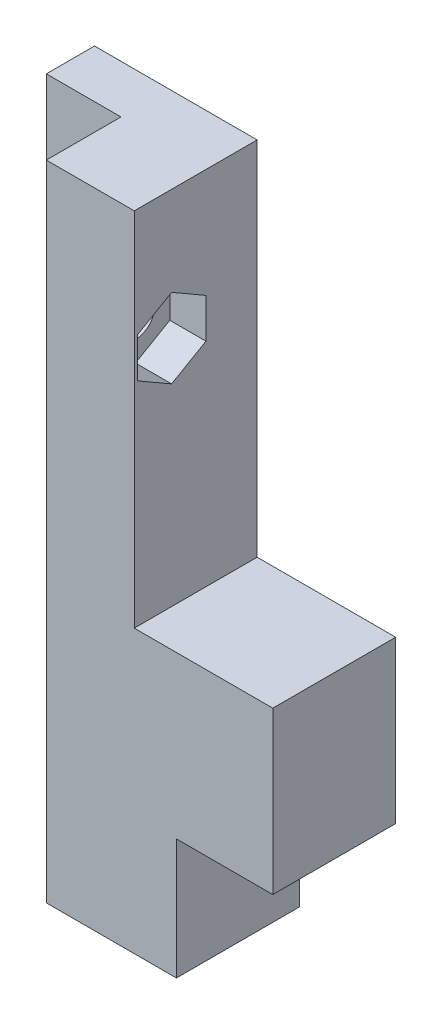
from build123d import *

# Parameters (mm, degrees)
SALIENTE_EXTRUIR1_DEPTH = 4
SALIENTE_EXTRUIR2_DEPTH = 6.2
CORTAR_EXTRUIR1_REACH   = 20.8
CROQUIS3_R              = 1.6
CORTAR_EXTRUIR2_DEPTH   = 3
SALIENTE_EXTRUIR3_DEPTH = 8.4
SALIENTE_EXTRUIR4_DEPTH = 10


with BuildPart() as part:
    # Croquis1 → Saliente-Extruir1 (new body)
    with BuildSketch(Plane.XY):
        Polygon((0, 0), (25, 0), (25, 5), (13.5, 5), (13.5, 35), (0, 35), align=None)
    extrude(amount=SALIENTE_EXTRUIR1_DEPTH)

    # Croquis2 → Saliente-Extruir2 (add)
    with BuildSketch(Plane.XY.offset(4)):
        Polygon((6.2, 35), (6.2, 0), (25, 0), (25, 5), (13.5, 5), (13.5, 35), align=None)
    extrude(amount=SALIENTE_EXTRUIR2_DEPTH)

    # Croquis3 → Cortar-Extruir1 (cut, up to next)
    with BuildSketch(Plane.ZY.offset(-6.2), mode=Mode.PRIVATE) as cortar_extruir1_sk1:
        with Locations((7.1, 24.3)):
            Circle(CROQUIS3_R)
    cortar_extruir1_tool1 = extrude(cortar_extruir1_sk1.sketch, amount=-CORTAR_EXTRUIR1_REACH, mode=Mode.PRIVATE) & part.part
    add(cortar_extruir1_tool1.solids().sort_by_distance((6.2, 24.3, 7.1))[0], mode=Mode.SUBTRACT)

    # Croquis4 → Cortar-Extruir2 (cut)
    with BuildSketch(Plane(origin=(13.5, 0, 0), x_dir=(0, 0, -1), z_dir=(1, 0, 0))):
        Polygon((-7.1, 27.590896534), (-9.95, 25.945448267), (-9.95, 22.654551733), (-7.1, 21.009103466), (-4.25, 22.654551733), (-4.25, 25.945448267), align=None)
    extrude(amount=-CORTAR_EXTRUIR2_DEPTH, mode=Mode.SUBTRACT)

    # Croquis5 → Saliente-Extruir3 (add)
    with BuildSketch(Plane.XZ):
        Polygon((0, 0), (25, 0), (25, 10.2), (6.2, 10.2), (6.2, 4), (0, 4), align=None)
    extrude(amount=SALIENTE_EXTRUIR3_DEPTH)

    # Croquis6 → Saliente-Extruir4 (add)
    with BuildSketch(Plane.XZ.offset(8.4)):
        Polygon((17, 0), (17, 10.2), (6.2, 10.2), (6.2, 4), (0, 4), (0, 0), align=None)
    extrude(amount=SALIENTE_EXTRUIR4_DEPTH)


solid = part.part
